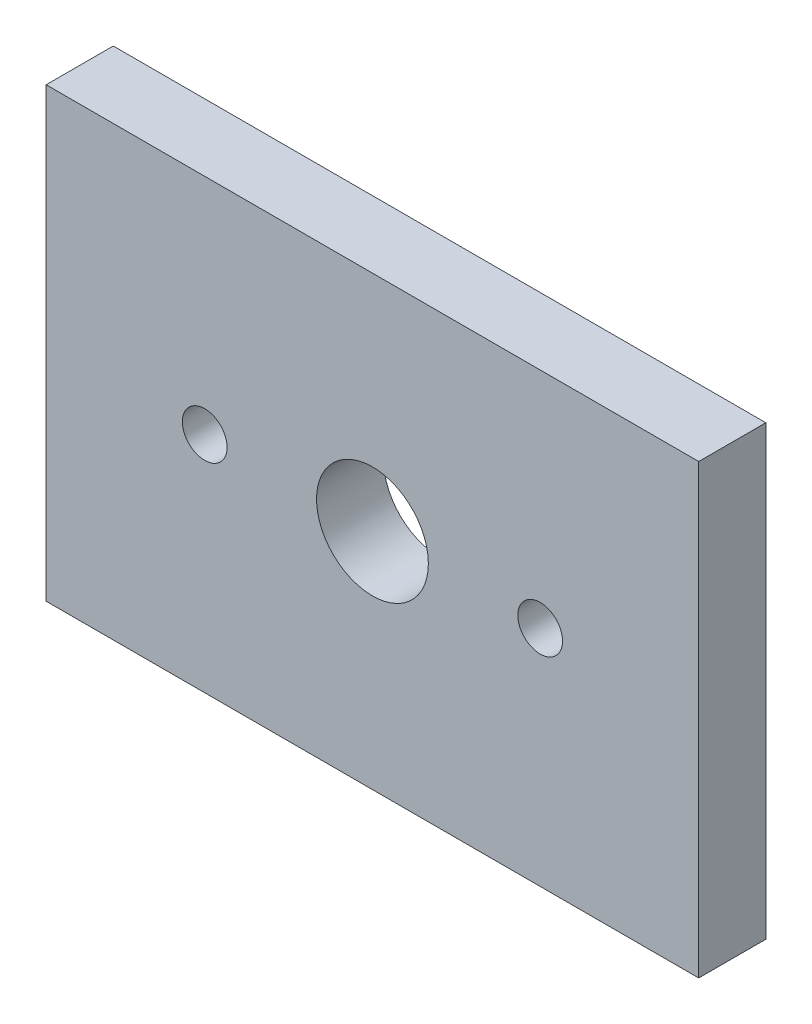
from build123d import *

# Parameters (mm, degrees)
SKETCH_1_W              = 29.177684157
SKETCH_1_H              = 20
EXTRUDE_1_DEPTH         = 3
SKETCH2_R               = 2
BOSS_EXTRUDE3_DEPTH     = 3
SKETCH_2_R              = 2.5
SKETCH_2_R_2            = 1
CUT_EXTRUDE1_DEPTH      = 10
CUT_EXTRUDE1_DEPTH_BACK = 6


with BuildPart() as part:
    # 草圖1 → 填料-伸長1 (new body)
    with BuildSketch(Plane.XY):
        with Locations((8.493155936, 3.641078838)):
            Rectangle(SKETCH_1_W, SKETCH_1_H)
    extrude(amount=EXTRUDE_1_DEPTH)

    # Sketch2 → Boss-Extrude3 (add)
    with BuildSketch(Plane.XY):
        with Locations((15.993155937, 3.641078838)):
            Circle(SKETCH2_R)
        with Locations((0.993155937, 3.641078838)):
            Circle(SKETCH2_R)
    extrude(amount=-BOSS_EXTRUDE3_DEPTH)

    # 草圖2 → Cut-Extrude1 (cut, two sides)
    with BuildSketch(Plane.XY) as cut_extrude1_sk:
        with Locations((8.493155937, 3.641078838)):
            Circle(SKETCH_2_R)
        with Locations((15.993155937, 3.641078838)):
            Circle(SKETCH_2_R_2)
        with Locations((0.993155937, 3.641078838)):
            Circle(SKETCH_2_R_2)
    extrude(amount=CUT_EXTRUDE1_DEPTH, mode=Mode.SUBTRACT)
    extrude(cut_extrude1_sk.sketch, amount=-CUT_EXTRUDE1_DEPTH_BACK, mode=Mode.SUBTRACT)


solid = part.part
